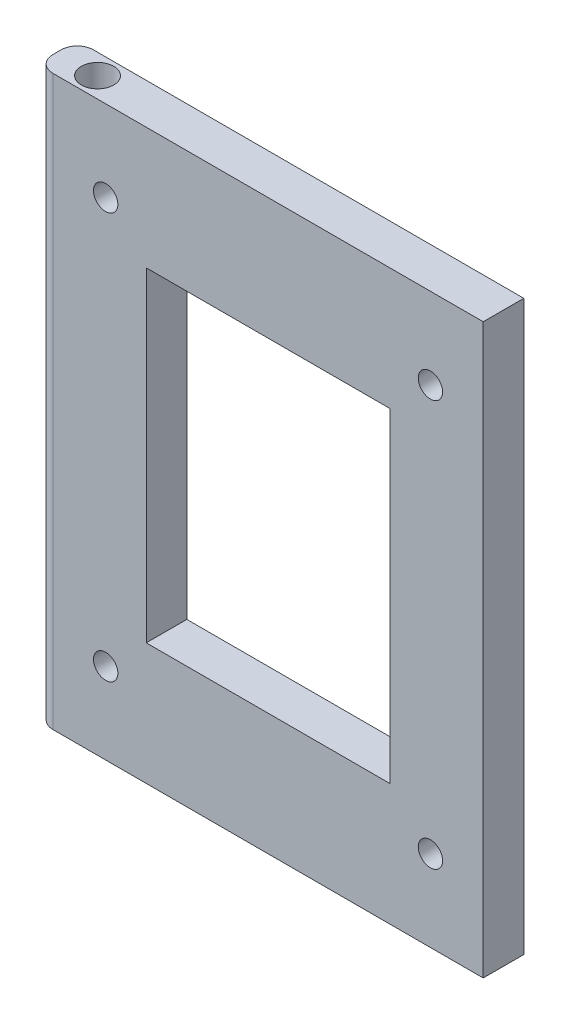
from build123d import *

# Parameters (mm, degrees)
SKETCH1_W           = 70
SKETCH1_H           = 55
BOSS_EXTRUDE1_DEPTH = 5
SKETCH2_R           = 2
CUT_EXTRUDE1_DEPTH  = 4.5
SKETCH3_R           = 2
CUT_EXTRUDE2_DEPTH  = 4.5
FILLET1_R           = 2
SKETCH4_R           = 1.5
SKETCH4_W           = 30
SKETCH4_H           = 40
CUT_EXTRUDE3_DEPTH  = 6


with BuildPart() as part:
    # Sketch1 → Boss-Extrude1 (new body)
    with BuildSketch(Plane(origin=(0, 0, 0), x_dir=(0, 1, 0), z_dir=(0, 0, 1))):
        with Locations((35, 27.5)):
            Rectangle(SKETCH1_W, SKETCH1_H)
    extrude(amount=BOSS_EXTRUDE1_DEPTH)

    # Sketch2 → Cut-Extrude1 (cut)
    with BuildSketch(Plane(origin=(0, 70, 0), x_dir=(-1, 0, 0), z_dir=(0, 1, 0))):
        with Locations((50, 2.5)):
            Circle(SKETCH2_R)
    extrude(amount=-CUT_EXTRUDE1_DEPTH, mode=Mode.SUBTRACT)

    # Sketch3 → Cut-Extrude2 (cut)
    with BuildSketch(Plane.XZ):
        with Locations((-50, 2.5)):
            Circle(SKETCH3_R)
    extrude(amount=-CUT_EXTRUDE2_DEPTH, mode=Mode.SUBTRACT)

    # Fillet1
    fillet1_edges = [part.edges().sort_by_distance(p)[0] for p in [
        (-55, 35, 5),
        (-55, 35, 0),
    ]]
    fillet(fillet1_edges, radius=FILLET1_R)

    # Sketch4 → Cut-Extrude3 (cut, through all)
    with BuildSketch(Plane.XY.offset(5)):
        with Locations((-6.5, 60)):
            Circle(SKETCH4_R)
        with Locations((-46.5, 60)):
            Circle(SKETCH4_R)
        with Locations((-6.5, 10)):
            Circle(SKETCH4_R)
        with Locations((-46.5, 10)):
            Circle(SKETCH4_R)
        with Locations((-26.5, 35)):
            Rectangle(SKETCH4_W, SKETCH4_H)
    extrude(amount=-CUT_EXTRUDE3_DEPTH, mode=Mode.SUBTRACT)


solid = part.part
